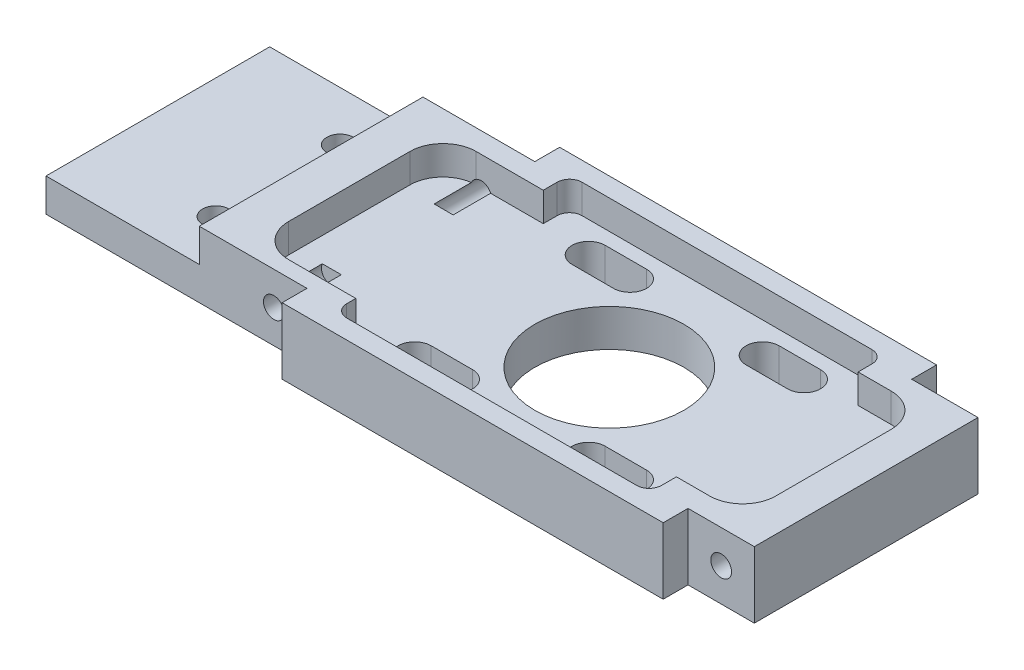
from build123d import *

# Parameters (mm, degrees)
EXTRUDE_1_DEPTH      = 8
SKETCH_2_W           = 18.5
SKETCH_2_H           = 27
CUT_EXTRUDE_1_DEPTH  = 4
SKETCH_3_R           = 1.6
CUT_EXTRUDE_2_DEPTH  = 5
SKETCH_4_R           = 9
CUT_EXTRUDE_3_DEPTH  = 9
CUT_EXTRUDE_4_DEPTH  = 3.5
SKETCH_6_R           = 1.25
CUT_EXTRUDE_8_DEPTH  = 7
SKETCH_7_R           = 1.25
CUT_EXTRUDE_9_DEPTH  = 7
SKETCH_8_R           = 1.25
CUT_EXTRUDE_10_DEPTH = 7
SKETCH_9_R           = 1.25
CUT_EXTRUDE_11_DEPTH = 7


with BuildPart() as part:
    # Эскиз1 → Бобышка-Вытянуть1 (new body)
    with BuildSketch(Plane(origin=(0, 0, 0), x_dir=(1, 0, 0), z_dir=(0, 1, 0))):
        Polygon((43, 13.5), (43, -13.5), (35, -13.5), (35, -16.5), (-11, -16.5), (-11, -13.5), (-42.5, -13.5), (-42.5, 13.5), (-10.5, 13.5), (-10.5, 16.5), (35, 16.5), (35, 13.5), align=None)
    extrude(amount=EXTRUDE_1_DEPTH)

    # Эскиз2 → Вырез-Вытянуть1 (cut)
    with BuildSketch(Plane(origin=(0, 8, 0), x_dir=(1, 0, 0), z_dir=(0, 1, 0))):
        with Locations((-33.25, 0)):
            Rectangle(SKETCH_2_W, SKETCH_2_H)
    extrude(amount=-CUT_EXTRUDE_1_DEPTH, mode=Mode.SUBTRACT)

    # Эскиз3 → Вырез-Вытянуть2 (cut, through all)
    with BuildSketch(Plane(origin=(0, 4, 0), x_dir=(1, 0, 0), z_dir=(0, 1, 0))):
        with Locations(Location((-28, 7.5, 0), (0, 0, 270))):  # turned: the seam where the file's is
            Circle(SKETCH_3_R)
        with Locations(Location((-28, -7.5, 0), (0, 0, 90))):  # turned: the seam where the file's is
            Circle(SKETCH_3_R)
    extrude(amount=-CUT_EXTRUDE_2_DEPTH, mode=Mode.SUBTRACT)

    # Эскиз4 → Вырез-Вытянуть3 (cut, through all)
    with BuildSketch(Plane.XZ):
        with Locations(Location((12, 0, 0), (0, 0, 270))):  # turned: the seam where the file's is
            Circle(SKETCH_4_R)
        with BuildLine():
            Line((20, 12.5), (25, 12.5))
            ThreePointArc((25, 12.5), (27, 10.5), (25, 8.5))
            Line((25, 8.5), (20, 8.5))
            ThreePointArc((20, 8.5), (18, 10.5), (20, 12.5))
        make_face()
        with BuildLine():
            Line((4, 12.5), (-1, 12.5))
            ThreePointArc((-1, 12.5), (-3, 10.5), (-1, 8.5))
            Line((-1, 8.5), (4, 8.5))
            ThreePointArc((4, 8.5), (6, 10.5), (4, 12.5))
        make_face()
        with BuildLine():
            Line((20, -12.5), (25, -12.5))
            ThreePointArc((25, -12.5), (27, -10.5), (25, -8.5))
            Line((25, -8.5), (20, -8.5))
            ThreePointArc((20, -8.5), (18, -10.5), (20, -12.5))
        make_face()
        with BuildLine():
            Line((4, -12.5), (-1, -12.5))
            ThreePointArc((-1, -12.5), (-3, -10.5), (-1, -8.5))
            Line((-1, -8.5), (4, -8.5))
            ThreePointArc((4, -8.5), (6, -10.5), (4, -12.5))
        make_face()
    extrude(amount=-CUT_EXTRUDE_3_DEPTH, mode=Mode.SUBTRACT)

    # Эскиз5 → Вырез-Вытянуть4 (cut)
    with BuildSketch(Plane(origin=(0, 8, 0), x_dir=(1, 0, 0), z_dir=(0, 1, 0))):
        with BuildLine():
            Line((-19.099474061, 7.023433075), (-19.099474061, -7.604302917))
            ThreePointArc((-19.099474061, -7.604302917), (-17.927901185, -10.432730042), (-15.099474061, -11.604302917))
            Line((-15.099474061, -11.604302917), (-7, -11.604302917))
            Line((-7, -11.604302917), (-7, -12.7))
            ThreePointArc((-7, -12.7), (-6.560660172, -13.760660172), (-5.5, -14.2))
            Line((-5.5, -14.2), (29.5, -14.2))
            ThreePointArc((29.5, -14.2), (30.560660172, -13.760660172), (31, -12.7))
            Line((31, -12.7), (31, -10.901181177))
            Line((31, -10.901181177), (35, -10.901181177))
            ThreePointArc((35, -10.901181177), (37.828427125, -9.729608302), (39, -6.901181177))
            Line((39, -6.901181177), (39, 7.023433075))
            ThreePointArc((39, 7.023433075), (37.828427125, 9.8518602), (35, 11.023433075))
            Line((35, 11.023433075), (31, 11.023433075))
            Line((31, 11.023433075), (31, 12.7))
            ThreePointArc((31, 12.7), (30.560660172, 13.760660172), (29.5, 14.2))
            Line((29.5, 14.2), (-5.5, 14.2))
            ThreePointArc((-5.5, 14.2), (-6.560660172, 13.760660172), (-7, 12.7))
            Line((-7, 12.7), (-7, 11.023433075))
            Line((-7, 11.023433075), (-15.099474061, 11.023433075))
            ThreePointArc((-15.099474061, 11.023433075), (-17.927901185, 9.8518602), (-19.099474061, 7.023433075))
        make_face()
    extrude(amount=-CUT_EXTRUDE_4_DEPTH, mode=Mode.SUBTRACT)

    # Эскиз6 → Вырез-Вытянуть8 (cut)
    with BuildSketch(Plane.XY.offset(13.5)):
        with Locations((39, 4)):
            Circle(SKETCH_6_R)
    extrude(amount=-CUT_EXTRUDE_8_DEPTH, mode=Mode.SUBTRACT)

    # Эскиз7 → Вырез-Вытянуть9 (cut)
    with BuildSketch(Plane.XY.offset(13.5)):
        with Locations((-15, 4)):
            Circle(SKETCH_7_R)
    extrude(amount=-CUT_EXTRUDE_9_DEPTH, mode=Mode.SUBTRACT)

    # Эскиз8 → Вырез-Вытянуть10 (cut)
    with BuildSketch(Plane(origin=(0, 0, -13.5), x_dir=(-1, 0, 0), z_dir=(0, 0, -1))):
        with Locations(Location((-39, 4, 0), (0, 0, 180))):  # turned: the seam where the file's is
            Circle(SKETCH_8_R)
    extrude(amount=-CUT_EXTRUDE_10_DEPTH, mode=Mode.SUBTRACT)

    # Эскиз9 → Вырез-Вытянуть11 (cut)
    with BuildSketch(Plane(origin=(0, 0, -13.5), x_dir=(-1, 0, 0), z_dir=(0, 0, -1))):
        with Locations((14.5, 4)):
            Circle(SKETCH_9_R)
    extrude(amount=-CUT_EXTRUDE_11_DEPTH, mode=Mode.SUBTRACT)


solid = part.part
